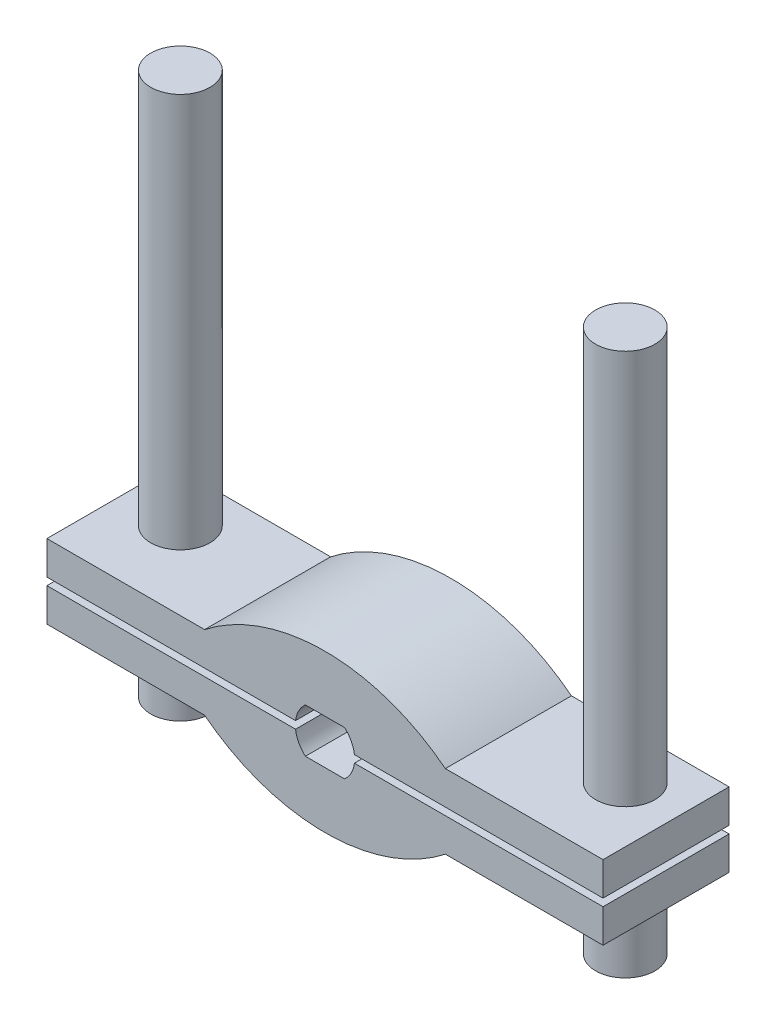
from build123d import *

# Parameters (mm, degrees)
EXTRUDE_1_DEPTH     = 34
EXTRUDE_1_2_DEPTH   = 34
SKETCH_3_R          = 8
EXTRUDE_2_DEPTH     = 106.4
SKETCH_3_2_R        = 8
EXTRUDE_3_DEPTH     = 40
SKETCH_4_R          = 8.25
CUT_EXTRUDE_1_DEPTH = 9


with BuildPart() as part:
    # Эскиз1 → Бобышка-Вытянуть1 (new body)
    with BuildSketch(Plane.XY):
        with BuildLine():
            Line((0, 21.2), (0, 6))
            Line((0, 6), (-5.291502622, 6))
            ThreePointArc((-5.291502622, 6), (-7.071067812, 3.741657387), (-7.937253933, 1))
            Line((-7.937253933, 1), (-75, 1))
            Line((-75, 1), (-75, 10))
            Line((-75, 10), (-32.469488078, 10))
            ThreePointArc((-32.469488078, 10), (-17.17343629, 18.321326505), (0, 21.2))
        make_face()
    extrude(amount=-EXTRUDE_1_DEPTH)

    # Эскиз3 → Бобышка-Вытянуть2 (add)
    with BuildSketch(Plane(origin=(0, 10, 0), x_dir=(1, 0, 0), z_dir=(0, 1, 0))):
        with Locations((-60, 21)):
            Circle(SKETCH_3_R)
    extrude(amount=EXTRUDE_2_DEPTH)

    # Эскиз3<2> → Бобышка-Вытянуть3 (add)
    with BuildSketch(Plane(origin=(0, 10, 0), x_dir=(1, 0, 0), z_dir=(0, 1, 0))):
        with Locations((-60, 21)):
            Circle(SKETCH_3_2_R)
    extrude(amount=-EXTRUDE_3_DEPTH)

    # Зеркальное отражение1: part across plane


with BuildPart() as body_2:
    # Эскиз1 → Extrude 1 2 (new body)
    with BuildSketch(Plane.XY):
        with BuildLine():
            Line((0, -6), (-5.291502622, -6))
            ThreePointArc((-5.291502622, -6), (-7.071067812, -3.741657387), (-7.937253933, -1))
            Line((-7.937253933, -1), (-75, -1))
            Line((-75, -1), (-75, -10))
            Line((-75, -10), (-32.469488078, -10))
            ThreePointArc((-32.469488078, -10), (-17.17343629, -18.321326505), (0, -21.2))
            Line((0, -21.2), (0, -6))
        make_face()
    extrude(amount=-EXTRUDE_1_2_DEPTH)

    # Эскиз4 → Вырез-Вытянуть1 (cut)
    with BuildSketch(Plane.XZ.offset(10)):
        with Locations((-60, -21)):
            Circle(SKETCH_4_R)
    extrude(amount=-CUT_EXTRUDE_1_DEPTH, mode=Mode.SUBTRACT)

    # Mirror 1 2: body 2 across plane


with BuildPart() as part_1:
    add(part.part)
    add(part.part.mirror(Plane(origin=(0, -21.2, -111.672646408), x_dir=(0, 0, 1), z_dir=(1, 0, 0))))


with BuildPart() as body_2_1:
    add(body_2.part)
    add(body_2.part.mirror(Plane(origin=(0, -21.2, -111.672646408), x_dir=(0, 0, 1), z_dir=(1, 0, 0))))


solid = Compound([part_1.part, body_2_1.part])
